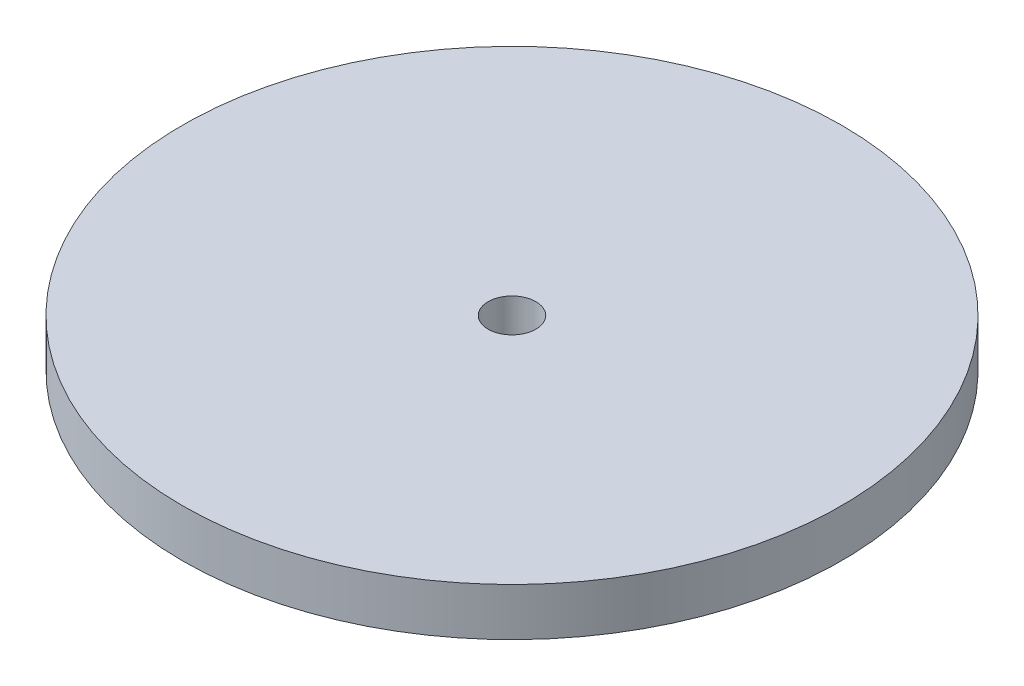
from build123d import *

# Parameters (mm, degrees)
SKETCH1_R           = 87.63
BOSS_EXTRUDE1_DEPTH = 12.7
SKETCH2_R           = 6.35
CUT_EXTRUDE1_DEPTH  = 12.7


with BuildPart() as part:
    # Sketch1 → Boss-Extrude1 (new body)
    with BuildSketch(Plane(origin=(0, 0, 0), x_dir=(1, 0, 0), z_dir=(0, 1, 0))):
        Circle(SKETCH1_R)
    extrude(amount=BOSS_EXTRUDE1_DEPTH)

    # Sketch2 → Cut-Extrude1 (cut)
    with BuildSketch(Plane(origin=(0, 12.7, 0), x_dir=(1, 0, 0), z_dir=(0, 1, 0))):
        Circle(SKETCH2_R)
    extrude(amount=-CUT_EXTRUDE1_DEPTH, mode=Mode.SUBTRACT)


solid = part.part
